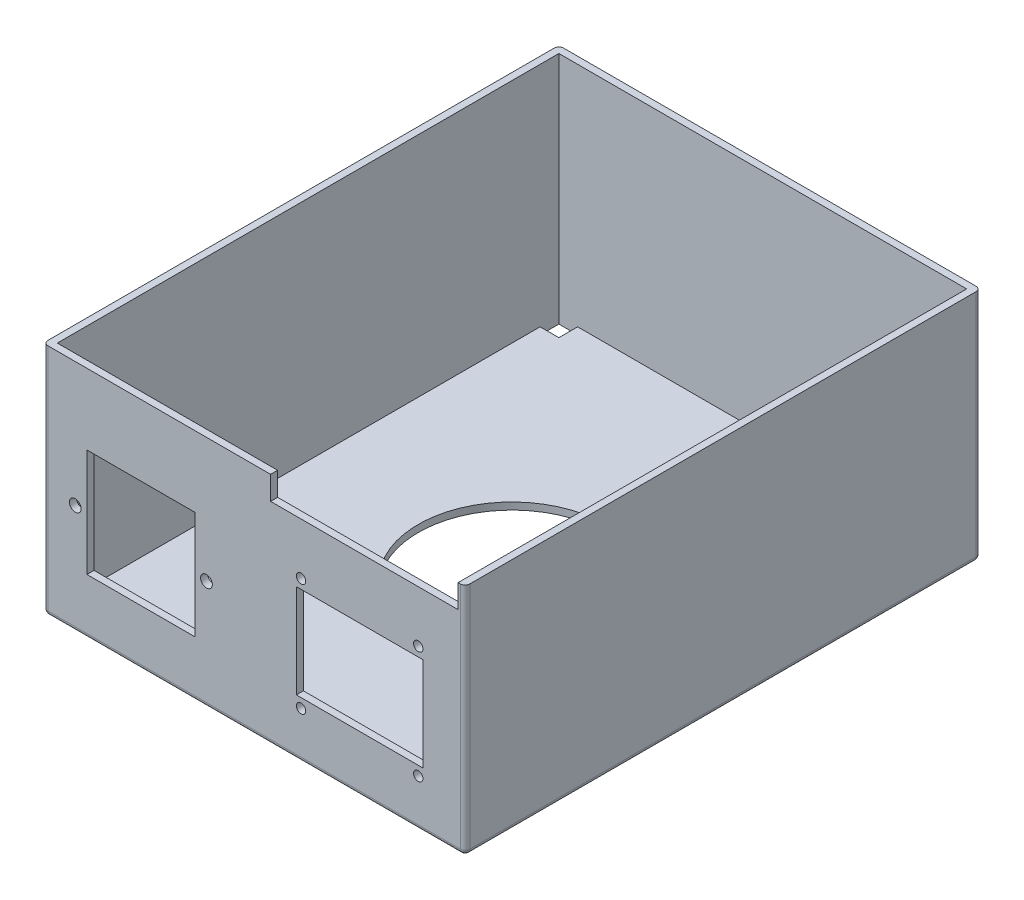
from build123d import *

# Parameters (mm, degrees)
SKETCH_4_W               = 90
SKETCH_4_H               = 110
EXTRUDE_2_DEPTH          = 50
SHELL_2_T                = -1.5
SKETCH_5_W               = 4
SKETCH_5_H               = 4
CUT_EXTRUDE_2_DEPTH      = 50
MIRROR_5_COPY_1_SKETCH_W = 4
MIRROR_5_COPY_1_SKETCH_H = 4
MIRROR_5_COPY_1_DEPTH    = 50
SKETCH_9_R               = 20
CUT_EXTRUDE_5_DEPTH      = 50
SKETCH_12_W              = 23
SKETCH_12_H              = 23
CUT_EXTRUDE_6_DEPTH      = 50
SKETCH_15_R              = 1.25
CUT_EXTRUDE_8_DEPTH      = 129
SKETCH_16_W              = 27
SKETCH_16_H              = 20
CUT_EXTRUDE_9_DEPTH      = 50
SKETCH_17_R              = 1
CUT_EXTRUDE_10_DEPTH     = 50
SKETCH_19_R              = 1
CUT_EXTRUDE_11_DEPTH     = 50
SKETCH_21_R              = 1
CUT_EXTRUDE_12_DEPTH     = 50
SKETCH_22_R              = 1
CUT_EXTRUDE_13_DEPTH     = 50
FILLET_1_R               = 1
FILLET_2_R               = 1
SKETCH_25_W              = 40
SKETCH_25_H              = 5
CUT_EXTRUDE_15_DEPTH     = 50


with BuildPart() as part:
    # 草图4 → 凸台-拉伸2 (new body)
    with BuildSketch(Plane(origin=(0, 0, 0), x_dir=(1, 0, 0), z_dir=(0, 1, 0))):
        Rectangle(SKETCH_4_W, SKETCH_4_H)
    extrude(amount=EXTRUDE_2_DEPTH)

    # 抽壳2
    shell_2_openings = [part.faces().sort_by_distance(p)[0] for p in [
        (0, 50, 0),
    ]]
    offset(amount=SHELL_2_T, openings=shell_2_openings, kind=Kind.INTERSECTION)

    # 草图5 → 切除-拉伸2 (cut)
    with BuildSketch(Plane(origin=(0, 1.5, 0), x_dir=(1, 0, 0), z_dir=(0, 1, 0))):
        with Locations((-41.5, 51.5)):
            Rectangle(SKETCH_5_W, SKETCH_5_H)
    cut_extrude_2 = extrude(amount=-CUT_EXTRUDE_2_DEPTH, mode=Mode.SUBTRACT)

    # 镜向4: 切除-拉伸2 across plane
    add(cut_extrude_2.mirror(Plane.XY), mode=Mode.SUBTRACT)

    # 镜向5: 切除-拉伸2 across plane
    add(cut_extrude_2.mirror(Plane(origin=(0, 0, 0), x_dir=(0, 0, 1), z_dir=(1, 0, 0))), mode=Mode.SUBTRACT)

    # 镜向5 copy 1 sketch → 镜向5 copy 1 (cut)
    with BuildSketch(Plane(origin=(0, 1.5, 0), x_dir=(-1, 0, 0), z_dir=(0, 1, 0))):
        with Locations((-41.5, 51.5)):
            Rectangle(MIRROR_5_COPY_1_SKETCH_W, MIRROR_5_COPY_1_SKETCH_H)
    extrude(amount=-MIRROR_5_COPY_1_DEPTH, mode=Mode.SUBTRACT)

    # 草图9 → 切除-拉伸5 (cut)
    with BuildSketch(Plane(origin=(0, 1.5, 0), x_dir=(1, 0, 0), z_dir=(0, 1, 0))):
        Circle(SKETCH_9_R)
    extrude(amount=-CUT_EXTRUDE_5_DEPTH, mode=Mode.SUBTRACT)

    # 草图12 → 切除-拉伸6 (cut)
    with BuildSketch(Plane.XY.offset(55)):
        with Locations((-24.177084585, 23.410301274)):
            Rectangle(SKETCH_12_W, SKETCH_12_H)
    extrude(amount=-CUT_EXTRUDE_6_DEPTH, mode=Mode.SUBTRACT)

    # 草图15 → 切除-拉伸8 (cut)
    with BuildSketch(Plane.XY.offset(-53.5)):
        with Locations((-10.177084585, 23.410301274)):
            Circle(SKETCH_15_R)
        with Locations((-38.177084585, 23.410301274)):
            Circle(SKETCH_15_R)
    extrude(amount=CUT_EXTRUDE_8_DEPTH, mode=Mode.SUBTRACT)

    # 草图16 → 切除-拉伸9 (cut)
    with BuildSketch(Plane.XY.offset(55)):
        with Locations((22.5, 22)):
            Rectangle(SKETCH_16_W, SKETCH_16_H)
    extrude(amount=-CUT_EXTRUDE_9_DEPTH, mode=Mode.SUBTRACT)

    # 草图17 → 切除-拉伸10 (cut)
    with BuildSketch(Plane.XY.offset(55)):
        with Locations((35, 34)):
            Circle(SKETCH_17_R)
    extrude(amount=-CUT_EXTRUDE_10_DEPTH, mode=Mode.SUBTRACT)

    # 草图19 → 切除-拉伸11 (cut)
    with BuildSketch(Plane.XY.offset(55)):
        with Locations((35, 10)):
            Circle(SKETCH_19_R)
    extrude(amount=-CUT_EXTRUDE_11_DEPTH, mode=Mode.SUBTRACT)

    # 草图21 → 切除-拉伸12 (cut)
    with BuildSketch(Plane.XY.offset(55)):
        with Locations((10, 34)):
            Circle(SKETCH_21_R)
    extrude(amount=-CUT_EXTRUDE_12_DEPTH, mode=Mode.SUBTRACT)

    # 草图22 → 切除-拉伸13 (cut)
    with BuildSketch(Plane.XY.offset(55)):
        with Locations((10, 10)):
            Circle(SKETCH_22_R)
    extrude(amount=-CUT_EXTRUDE_13_DEPTH, mode=Mode.SUBTRACT)

    # 圆角1
    fillet_1_edges = [part.edges().sort_by_distance(p)[0] for p in [
        (-45, 25, -55),
        (45, 25, -55),
        (45, 25, 55),
        (-45, 25, 55),
    ]]
    fillet(fillet_1_edges, radius=FILLET_1_R)

    # 圆角2
    fillet_2_edges = [part.edges().sort_by_distance(p)[0] for p in [
        (0, 0, -55),
        (-45, 0, 0),
        (45, 0, 0),
        (0, 0, 55),
        (44.707106781, 0, 54.707106781),
        (-44.707106781, 0, 54.707106781),
        (-44.707106781, 0, -54.707106781),
        (44.707106781, 0, -54.707106781),
    ]]
    fillet(fillet_2_edges, radius=FILLET_2_R)

    # 草图25 → 切除-拉伸15 (cut)
    with BuildSketch(Plane(origin=(0, 0, 53.5), x_dir=(-1, 0, 0), z_dir=(0, 0, -1))):
        with Locations((-23.5, 47.5)):
            Rectangle(SKETCH_25_W, SKETCH_25_H)
    extrude(amount=-CUT_EXTRUDE_15_DEPTH, mode=Mode.SUBTRACT)


solid = part.part
